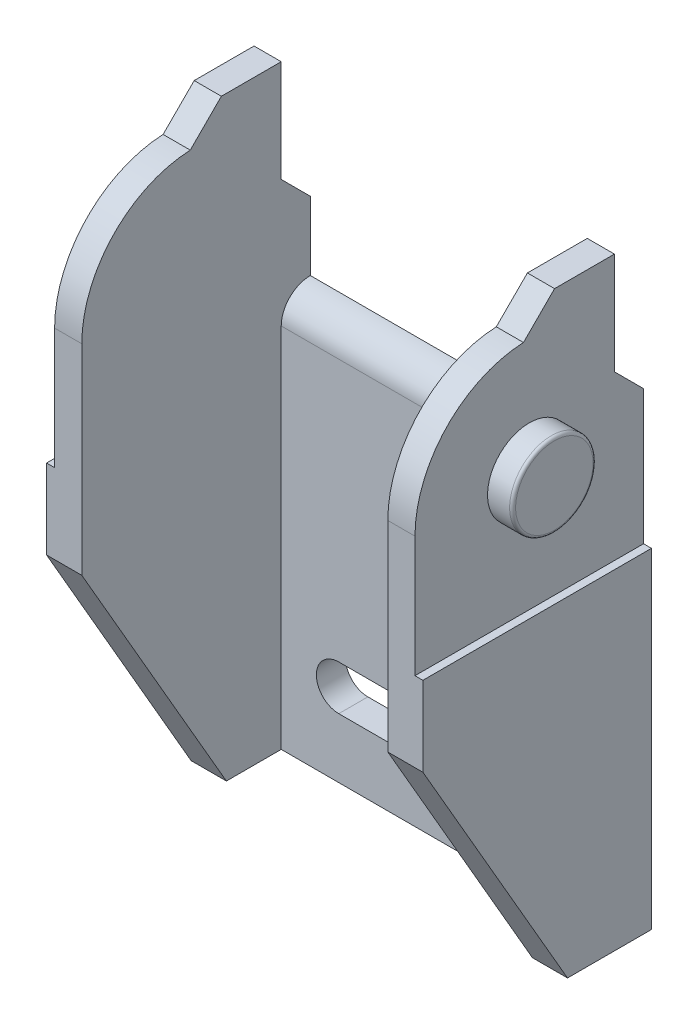
from build123d import *

# Parameters (mm, degrees)
BOSS_EXTRUDE1_DEPTH = 3.67
SKETCH2_W           = 3.67
SKETCH2_H           = 9.687937517
BOSS_EXTRUDE2_DEPTH = 9.735
SKETCH3_W           = 3.67
SKETCH3_H           = 26.515
BOSS_EXTRUDE3_DEPTH = 5.622062483
BOSS_EXTRUDE4_DEPTH = 20.5
SKETCH5_W           = 3.67
SKETCH5_H           = 15.31
BOSS_EXTRUDE5_DEPTH = 13.38
BOSS_EXTRUDE6_DEPTH = 2.35
SKETCH7_W           = 1.85
SKETCH7_H           = 17.78
CUT_EXTRUDE1_DEPTH  = 16.310000003
CUT_EXTRUDE2_REACH  = 27.99
SKETCH9_W           = 1.85
SKETCH9_H           = 17.78
CUT_EXTRUDE3_DEPTH  = 16.310000003
CUT_EXTRUDE4_REACH  = 26.67
CUT_EXTRUDE5_REACH  = 26.67
CUT_EXTRUDE6_DEPTH  = 26.99
CUT_EXTRUDE7_DEPTH  = 2.95
SKETCH15_W          = 1.68
SKETCH15_H          = 2.795
SKETCH16_W          = 1.68
SKETCH16_H          = 2.795
FILLET1_R           = 0.2
CUT_EXTRUDE8_DEPTH  = 1.31


with BuildPart() as part:
    # Sketch1 → Boss-Extrude1 (new body)
    with BuildSketch(Plane(origin=(-13.92, 0, 0), x_dir=(0, -1, 0), z_dir=(-1, 0, 0))):
        Polygon((19.9475, 5.622062483), (3.1675, 15.31), (3.1675, 5.622062483), align=None)
    extrude(amount=-BOSS_EXTRUDE1_DEPTH)

    # Sketch2 → Boss-Extrude2 (add)
    with BuildSketch(Plane(origin=(0, -3.1675, 0), x_dir=(-1, 0, 0), z_dir=(0, 1, 0))):
        with Locations((12.085, 10.466031242)):
            Rectangle(SKETCH2_W, SKETCH2_H)
    extrude(amount=BOSS_EXTRUDE2_DEPTH)

    # Sketch3 → Boss-Extrude3 (add)
    with BuildSketch(Plane(origin=(0, 0, 5.622062483), x_dir=(-1, 0, 0), z_dir=(0, 0, -1))):
        with Locations((12.085, -6.69)):
            Rectangle(SKETCH3_W, SKETCH3_H)
    extrude(amount=BOSS_EXTRUDE3_DEPTH)

    # Sketch4 → Boss-Extrude4 (add)
    with BuildSketch(Plane(origin=(-10.25, 0, 0), x_dir=(0, 0, -1), z_dir=(1, 0, 0))):
        with BuildLine():
            Line((3e-09, -19.9475), (-1.949999997, -19.9475))
            Line((-1.949999997, -19.9475), (-1.949999997, 4.6175))
            ThreePointArc((-1.949999997, 4.6175), (-1.37885822, 5.996358223), (3e-09, 6.5675))
            Line((3e-09, 6.5675), (3e-09, -19.9475))
        make_face()
    extrude(amount=BOSS_EXTRUDE4_DEPTH)

    # Sketch5 → Boss-Extrude5 (add)
    with BuildSketch(Plane(origin=(0, 6.5675, 0), x_dir=(-1, 0, 0), z_dir=(0, 1, 0))):
        with Locations((12.085, 7.655)):
            Rectangle(SKETCH5_W, SKETCH5_H)
    extrude(amount=BOSS_EXTRUDE5_DEPTH)

    # Sketch6 → Boss-Extrude6 (add)
    with BuildSketch(Plane(origin=(10.25, 0, 0), x_dir=(0, 0, -1), z_dir=(1, 0, 0))):
        Polygon((-15.31, -3.1675), (-15.31, 19.9475), (2e-09, 19.9475), (2e-09, -19.947499999), (-5.622062484, -19.947499999), align=None)
    extrude(amount=BOSS_EXTRUDE6_DEPTH)

    # Sketch7 → Cut-Extrude1 (cut, through all)
    with BuildSketch(Plane.XY.offset(15.31)):
        with Locations((12.995, 11.0575)):
            Rectangle(SKETCH7_W, SKETCH7_H)
    extrude(amount=-CUT_EXTRUDE1_DEPTH, mode=Mode.SUBTRACT)

    # Sketch8 → Cut-Extrude2 (cut, up to next)
    with BuildSketch(Plane(origin=(12.07, 0, 0), x_dir=(0, 0, -1), z_dir=(1, 0, 0)), mode=Mode.PRIVATE) as cut_extrude2_sk1:
        with BuildLine():
            Line((-8.04306505, 17.864239052), (-5.959804102, 19.9475))
            Line((-5.959804102, 19.9475), (-15.31, 19.9475))
            Line((-15.31, 19.9475), (-15.31, 10.26298277))
            ThreePointArc((-15.31, 10.26298277), (-13.200981436, 15.521010933), (-8.04306505, 17.864239052))
        make_face()
    cut_extrude2_tool1 = extrude(cut_extrude2_sk1.sketch, amount=-CUT_EXTRUDE2_REACH, mode=Mode.PRIVATE) & part.part
    add(cut_extrude2_tool1.solids().sort_by_distance((12.07, 17.788809, 12.169828))[0], mode=Mode.SUBTRACT)

    # Sketch9 → Cut-Extrude3 (cut, through all)
    with BuildSketch(Plane.XY.offset(15.31)):
        with Locations((-12.995, 11.0575)):
            Rectangle(SKETCH9_W, SKETCH9_H)
    extrude(amount=-CUT_EXTRUDE3_DEPTH, mode=Mode.SUBTRACT)

    # Sketch10 → Cut-Extrude4 (cut, up to next)
    with BuildSketch(Plane.ZY.offset(12.07), mode=Mode.PRIVATE) as cut_extrude4_sk1:
        Polygon((1.95, 13.1175), (1.95, 19.9475), (0, 19.9475), (0, 11.1675), align=None)
    cut_extrude4_tool1 = extrude(cut_extrude4_sk1.sketch, amount=-CUT_EXTRUDE4_REACH, mode=Mode.PRIVATE) & part.part
    add(cut_extrude4_tool1.solids().sort_by_distance((-12.07, 16.024701, 0.934401))[0], mode=Mode.SUBTRACT)

    # Sketch11 → Cut-Extrude5 (cut, up to next)
    with BuildSketch(Plane.ZY.offset(12.07), mode=Mode.PRIVATE) as cut_extrude5_sk1:
        with BuildLine():
            Line((5.959804102, 19.9475), (8.04306505, 17.864239052))
            ThreePointArc((8.04306505, 17.864239052), (13.200981436, 15.521010933), (15.31, 10.26298277))
            Line((15.31, 10.26298277), (15.31, 19.9475))
            Line((15.31, 19.9475), (5.959804102, 19.9475))
        make_face()
    cut_extrude5_tool1 = extrude(cut_extrude5_sk1.sketch, amount=-CUT_EXTRUDE5_REACH, mode=Mode.PRIVATE) & part.part
    add(cut_extrude5_tool1.solids().sort_by_distance((-12.07, 17.788809, 12.169828))[0], mode=Mode.SUBTRACT)

    # Sketch12 → Cut-Extrude6 (cut, through all)
    with BuildSketch(Plane(origin=(12.07, 0, 0), x_dir=(0, 0, -1), z_dir=(1, 0, 0))):
        Polygon((-1.95, 19.9475), (-1.95, 13.1175), (0, 11.1675), (0, 19.9475), align=None)
    extrude(amount=-CUT_EXTRUDE6_DEPTH, mode=Mode.SUBTRACT)

    # Sketch13 → Cut-Extrude7 (cut, through all)
    with BuildSketch(Plane.XY.offset(1.949999997)):
        with BuildLine():
            Line((-6.395488685, -12.9475), (-2.104511315, -12.9475))
            ThreePointArc((-2.104511315, -12.9475), (-0.604511315, -14.4475), (-2.104511315, -15.9475))
            Line((-2.104511315, -15.9475), (-6.395488685, -15.9475))
            ThreePointArc((-6.395488685, -15.9475), (-7.895488685, -14.4475), (-6.395488685, -12.9475))
        make_face()
        with BuildLine():
            Line((2.104511315, -8.947499999), (6.395488685, -8.947499999))
            ThreePointArc((6.395488685, -8.947499999), (7.895488685, -10.447499999), (6.395488685, -11.947499999))
            Line((6.395488685, -11.947499999), (2.104511315, -11.947499999))
            ThreePointArc((2.104511315, -11.947499999), (0.604511315, -10.447499999), (2.104511315, -8.947499999))
        make_face()
    extrude(amount=-CUT_EXTRUDE7_DEPTH, mode=Mode.SUBTRACT)

    # Sketch15 → Revolve1 (revolve)
    with BuildSketch(Plane.XY.offset(7.655)):
        with Locations((12.91, 11.61)):
            Rectangle(SKETCH15_W, SKETCH15_H)
    revolve(axis=Axis((12.07, 10.2125, 7.655), (1, 0, 0)))

    # Sketch16 → Revolve2 (revolve)
    with BuildSketch(Plane.XY.offset(7.655)):
        with Locations((-12.91, 11.61)):
            Rectangle(SKETCH16_W, SKETCH16_H)
    revolve(axis=Axis((-13.75, 10.2125, 7.655), (1, 0, 0)))

    # Fillet1
    fillet1_edges = [part.edges().sort_by_distance(p)[0] for p in [
        (13.75, 7.4175, 7.655),
        (-13.75, 7.4175, 7.655),
    ]]
    fillet(fillet1_edges, radius=FILLET1_R)

    # Sketch17 → Cut-Extrude8 (cut)
    with BuildSketch(Plane(origin=(-13.92, -19.9475, 5.622062483), x_dir=(0, 0, 1), z_dir=(-1, 0, 0))):
        Polygon((9.687937517, 22.115), (-5.622062486, 22.115), (-5.622062483, 0), (0, 0), (9.687937517, 16.78), align=None)
    extrude(amount=-CUT_EXTRUDE8_DEPTH, mode=Mode.SUBTRACT)


solid = part.part
